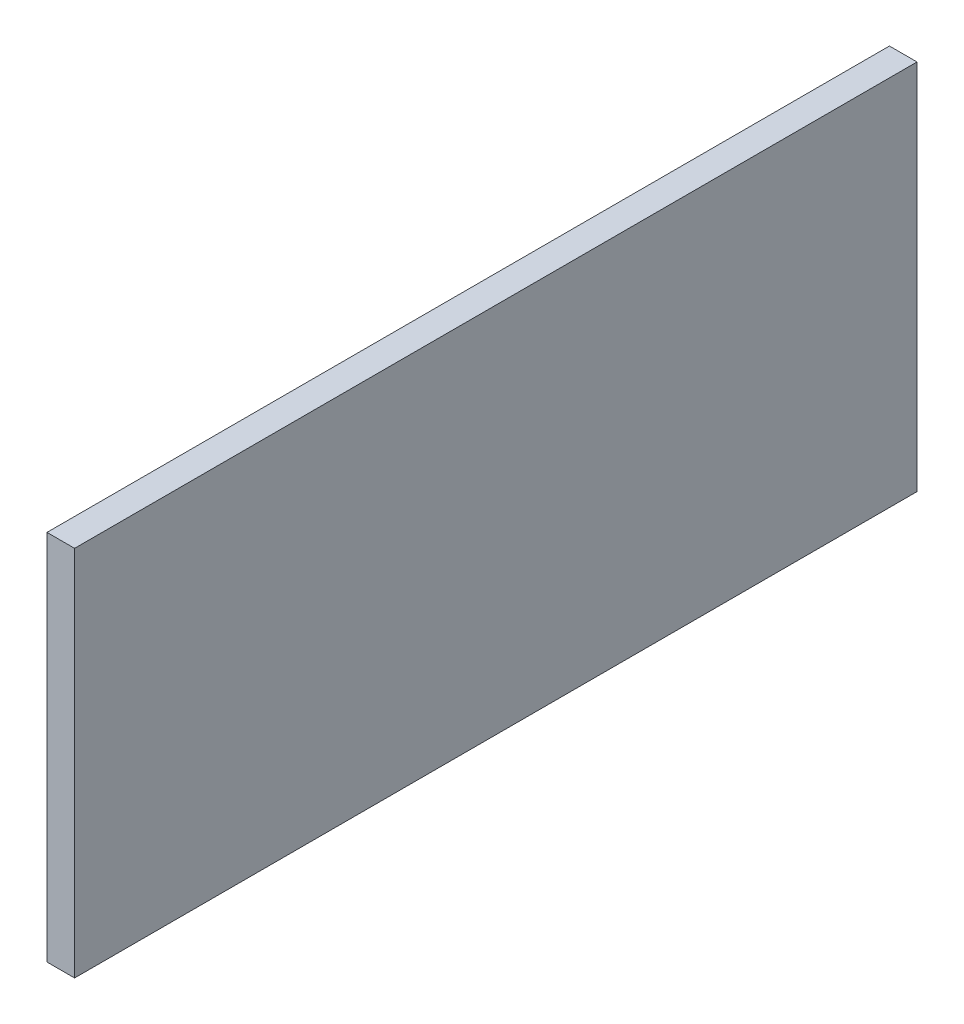
from build123d import *

# Parameters (mm, degrees)
ESQUISSE1_W        = 15.25
ESQUISSE1_H        = 205.5
BOSS_EXTRU_1_DEPTH = 465.25


with BuildPart() as part:
    # Esquisse1 → Boss.-Extru.1 (new body)
    with BuildSketch(Plane.XY):
        with Locations((-159.789847162, 82.563864629)):
            Rectangle(ESQUISSE1_W, ESQUISSE1_H)
    extrude(amount=BOSS_EXTRU_1_DEPTH)


solid = part.part
